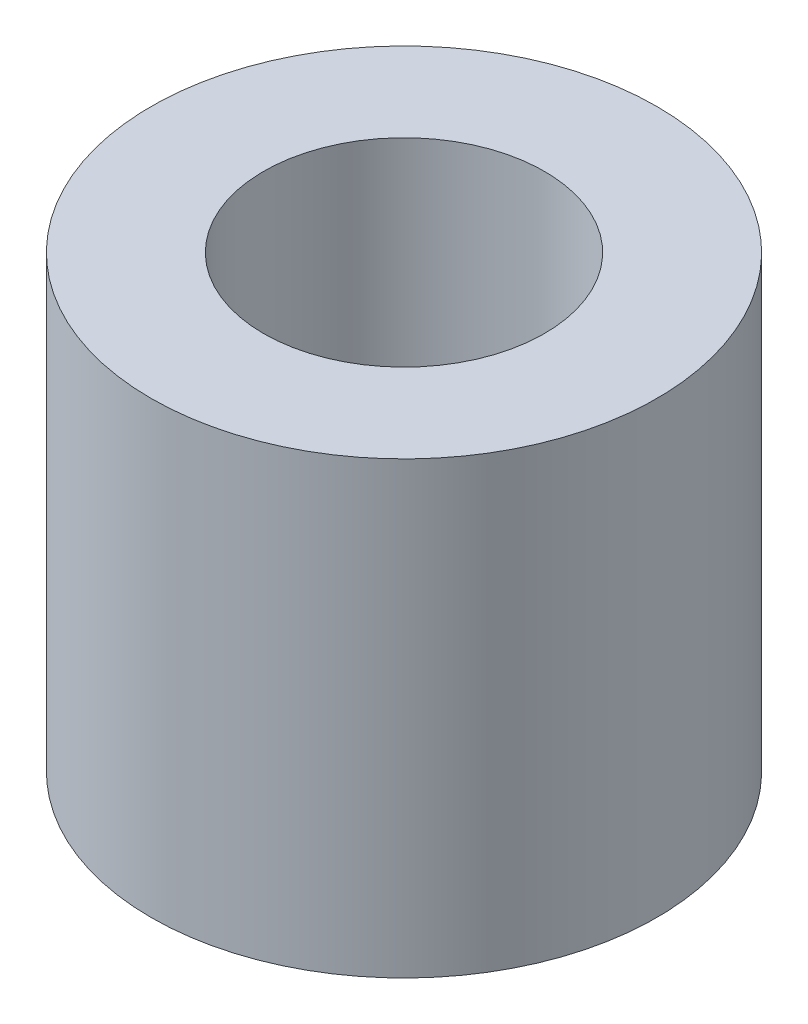
from build123d import *

# Parameters (mm, degrees)
SKETCH1_R           = 5.715
SKETCH1_R_2         = 3.175
BOSS_EXTRUDE1_DEPTH = 10.16


with BuildPart() as part:
    # Sketch1 → Boss-Extrude1 (new body)
    with BuildSketch(Plane(origin=(0, 0, 0), x_dir=(1, 0, 0), z_dir=(0, 1, 0))):
        Circle(SKETCH1_R)
        Circle(SKETCH1_R_2, mode=Mode.SUBTRACT)
    extrude(amount=BOSS_EXTRUDE1_DEPTH)


solid = part.part
